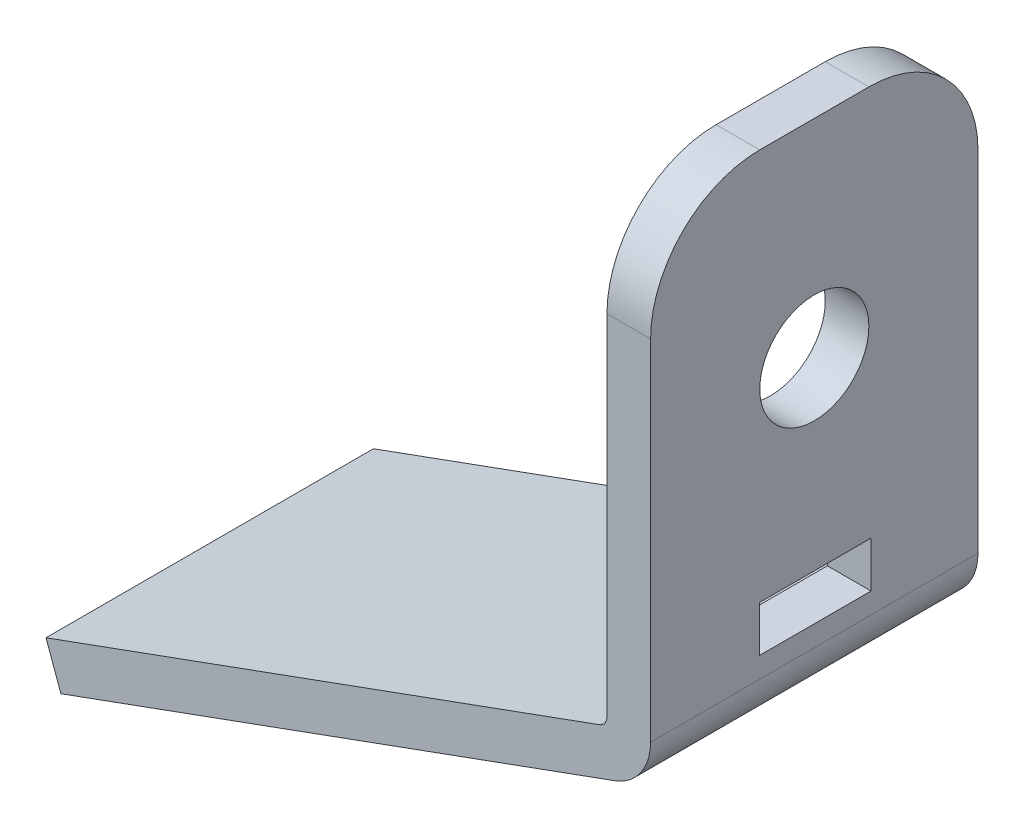
from build123d import *

# Parameters (mm, degrees)
DODANIE_WYCI_GNI_CIE1_DEPTH = 15
SZKIC2_R                    = 2.5
WYTNIJ_WYCI_GNI_CIE3_DEPTH  = 15
SZKIC4_W                    = 5.1
SZKIC4_H                    = 2.1
WYTNIJ_WYCI_GNI_CIE8_DEPTH  = 15
ZAOKR_GLENIE1_R             = 5


with BuildPart() as part:
    # Szkic1 → Dodanie-wyciągnięcie1 (new body)
    with BuildSketch(Plane.XY):
        with BuildLine():
            Line((0.355050358, -378.672211739), (-25.016650403, -387.906755609))
            Line((-25.016650403, -387.906755609), (-25.70069069, -386.027370367))
            Line((-25.70069069, -386.027370367), (-0.328989928, -376.792826498))
            ThreePointArc((-0.328989928, -376.792826498), (-0.090423978, -376.609768405), (0, -376.322980187))
            Line((0, -376.322980187), (0, -375.320100819))
            Line((0, -375.320100819), (0, -373.324775164))
            Line((0, -373.324775164), (0, -360.320100819))
            Line((0, -360.320100819), (0, -355.320100819))
            Line((0, -355.320100819), (2, -355.320100819))
            Line((2, -355.320100819), (2, -360.320100819))
            Line((2, -360.320100819), (2, -375.320100819))
            Line((2, -375.320100819), (2, -376.322980187))
            ThreePointArc((2, -376.322980187), (1.547880111, -377.756921278), (0.355050358, -378.672211739))
        make_face()
    extrude(amount=-DODANIE_WYCI_GNI_CIE1_DEPTH)

    # Szkic2 → Wytnij-wyciągnięcie3 (cut)
    with BuildSketch(Plane(origin=(2, 0, 0), x_dir=(0, 0, -1), z_dir=(1, 0, 0))):
        with Locations((7.5, -364.820100819)):
            Circle(SZKIC2_R)
    extrude(amount=-WYTNIJ_WYCI_GNI_CIE3_DEPTH, mode=Mode.SUBTRACT)

    # Szkic4 → Wytnij-wyciągnięcie8 (cut)
    with BuildSketch(Plane(origin=(2, 0, 0), x_dir=(0, 0, -1), z_dir=(1, 0, 0))):
        with Locations((7.55, -374.322980187)):
            Rectangle(SZKIC4_W, SZKIC4_H)
    extrude(amount=-WYTNIJ_WYCI_GNI_CIE8_DEPTH, mode=Mode.SUBTRACT)

    # Zaokrąglenie1
    zaokr_glenie1_edges = [part.edges().sort_by_distance(p)[0] for p in [
        (1, -355.320100819, -15),
        (1, -355.320100819, 0),
    ]]
    fillet(zaokr_glenie1_edges, radius=ZAOKR_GLENIE1_R)


solid = part.part
